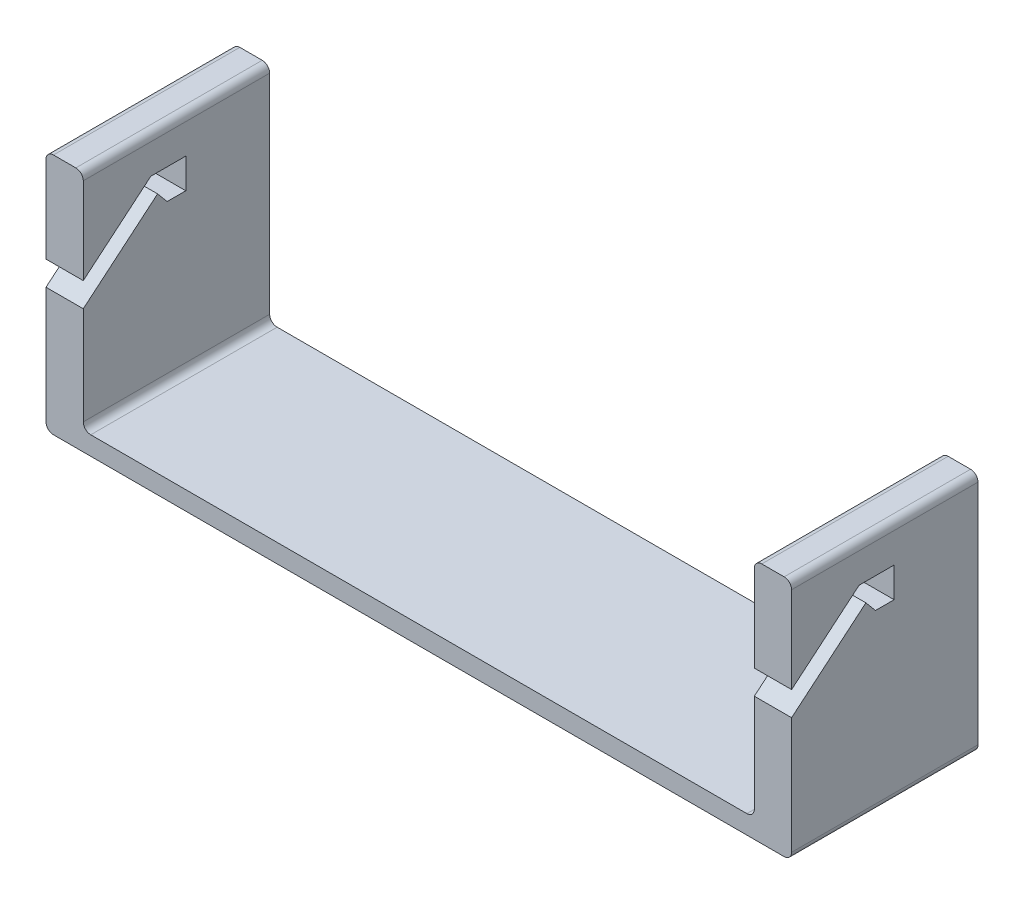
from build123d import *

# Parameters (mm, degrees)
SKETCH1_W           = 200
SKETCH1_H           = 50
BOSS_EXTRUDE1_DEPTH = 5
SKETCH2_W           = 50
SKETCH2_H           = 60
BOSS_EXTRUDE2_DEPTH = 10
CUT_EXTRUDE1_START  = -201
CUT_EXTRUDE1_DEPTH  = 202
FILLET1_R           = 2


with BuildPart() as part:
    # Sketch1 → Boss-Extrude1 (new body)
    with BuildSketch(Plane(origin=(0, 0, 0), x_dir=(1, 0, 0), z_dir=(0, 1, 0))):
        Rectangle(SKETCH1_W, SKETCH1_H)
    extrude(amount=BOSS_EXTRUDE1_DEPTH)

    # Sketch2 → Boss-Extrude2 (add)
    with BuildSketch(Plane.ZY.offset(100)):
        with Locations((0, 35)):
            Rectangle(SKETCH2_W, SKETCH2_H)
    boss_extrude2 = extrude(amount=-BOSS_EXTRUDE2_DEPTH)

    # Sketch3 → Cut-Extrude1 (cut)
    with BuildSketch(Plane.ZY.offset(100).offset(CUT_EXTRUDE1_START)):
        Polygon((25, 39.80474613), (6.89100161, 55), (-2.5, 55), (-2.5, 46.935822228), (2.5, 46.935822228), (5.071150439, 50), (25, 33.277709683), align=None)
    cut_extrude1 = extrude(amount=CUT_EXTRUDE1_DEPTH, mode=Mode.SUBTRACT)

    # Mirror1: Boss-Extrude2, Cut-Extrude1 across plane
    add(boss_extrude2.mirror(Plane(origin=(0, 0, 0), x_dir=(0, 0, 1), z_dir=(1, 0, 0))))
    add(cut_extrude1.mirror(Plane(origin=(0, 0, 0), x_dir=(0, 0, 1), z_dir=(1, 0, 0))), mode=Mode.SUBTRACT)

    # Fillet1
    fillet1_edges = [part.edges().sort_by_distance(p)[0] for p in [
        (-90, 5, 0),
        (-90, 65, 0),
        (-100, 65, 0),
        (100, 0, 0),
        (100, 65, 0),
        (-100, 0, 0),
        (90, 5, 0),
        (90, 65, 0),
    ]]
    fillet(fillet1_edges, radius=FILLET1_R)


solid = part.part
